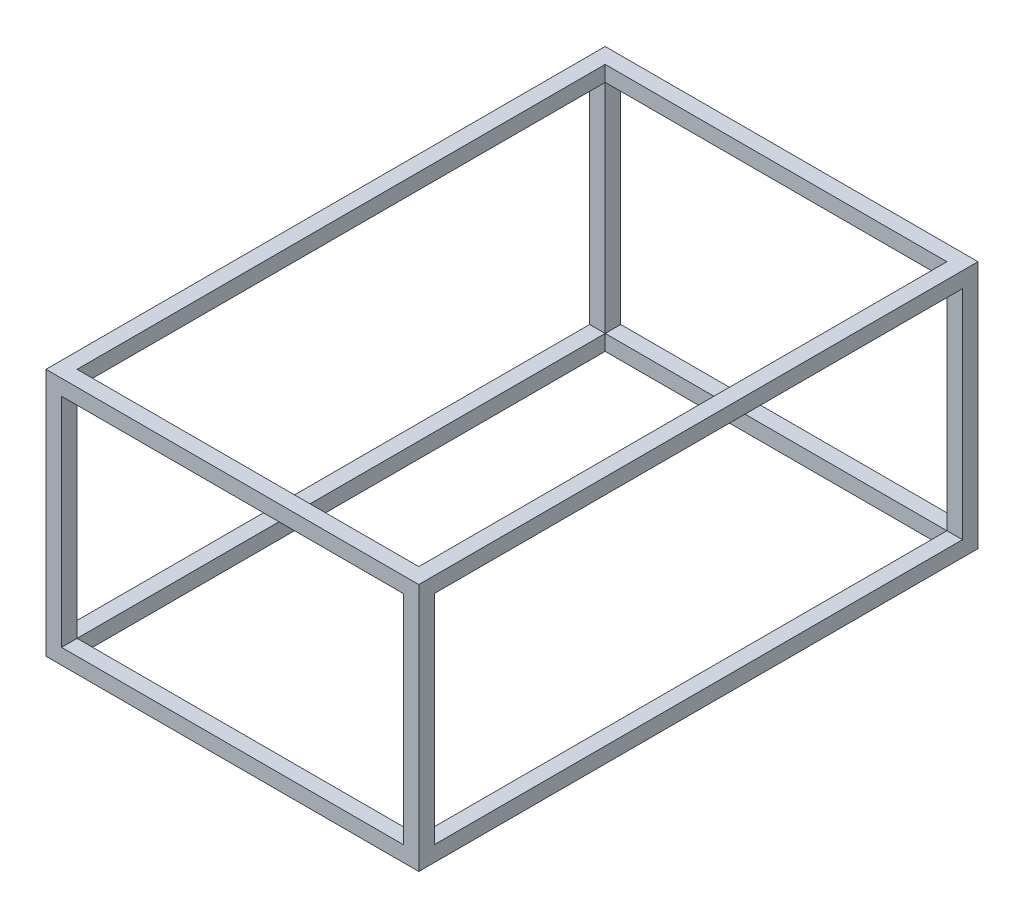
from build123d import *

# Parameters (mm, degrees)
SKETCH1_W           = 914.4
SKETCH1_H           = 609.6
SKETCH1_W_2         = 863.6
SKETCH1_H_2         = 558.8
BOSS_EXTRUDE1_DEPTH = 12.7
SKETCH2_W           = 25.4
SKETCH2_H           = 25.4
BOSS_EXTRUDE2_DEPTH = 381
SKETCH3_W           = 914.4
SKETCH3_H           = 609.6
SKETCH3_W_2         = 863.6
SKETCH3_H_2         = 558.8
BOSS_EXTRUDE3_DEPTH = 25.4


with BuildPart() as part:
    # Sketch1 → Boss-Extrude1 (new body, symmetric)
    with BuildSketch(Plane(origin=(0, 0, 0), x_dir=(0, 0, -1), z_dir=(0, 1, 0))):
        with Locations((457.2, 304.8)):
            Rectangle(SKETCH1_W, SKETCH1_H)
        with Locations((457.2, 304.8)):
            Rectangle(SKETCH1_W_2, SKETCH1_H_2, mode=Mode.SUBTRACT)
    extrude(amount=BOSS_EXTRUDE1_DEPTH, both=True)

    # Sketch2 → Boss-Extrude2 (add)
    with BuildSketch(Plane(origin=(0, 12.7, 0), x_dir=(0, 0, -1), z_dir=(0, 1, 0))):
        with Locations((12.7, 596.9)):
            Rectangle(SKETCH2_W, SKETCH2_H)
        with Locations((901.7, 596.9)):
            Rectangle(SKETCH2_W, SKETCH2_H)
        with Locations((901.7, 12.7)):
            Rectangle(SKETCH2_W, SKETCH2_H)
        with Locations((12.7, 12.7)):
            Rectangle(SKETCH2_W, SKETCH2_H)
    extrude(amount=BOSS_EXTRUDE2_DEPTH)

    # Sketch3 → Boss-Extrude3 (add)
    with BuildSketch(Plane(origin=(0, 393.7, 0), x_dir=(0, 0, -1), z_dir=(0, 1, 0))):
        with Locations((457.2, 304.8)):
            Rectangle(SKETCH3_W, SKETCH3_H)
        with Locations((457.2, 304.8)):
            Rectangle(SKETCH3_W_2, SKETCH3_H_2, mode=Mode.SUBTRACT)
    extrude(amount=-BOSS_EXTRUDE3_DEPTH)


solid = part.part
